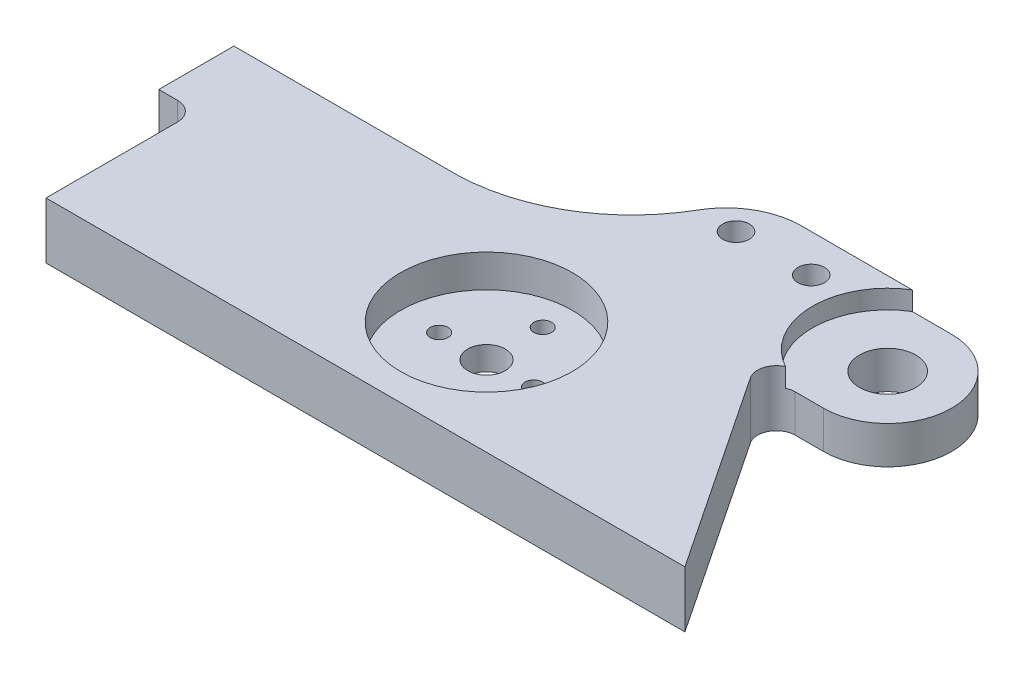
from build123d import *

# Parameters (mm, degrees)
SKETCH1_R           = 4.7625
SKETCH1_R_2         = 2.2479
SKETCH1_R_3         = 1.5
SKETCH1_R_4         = 3.175
BOSS_EXTRUDE1_DEPTH = 9.525
FILLET1_R           = 3.175
FILLET2_R           = 3.175
SKETCH2_R           = 14.5
CUT_EXTRUDE1_DEPTH  = 5.525
SKETCH3_R           = 12.7
CUT_EXTRUDE2_DEPTH  = 3.175


with BuildPart() as part:
    # Sketch1 → Boss-Extrude1 (new body)
    with BuildSketch(Plane(origin=(0, 0, 0), x_dir=(1, 0, 0), z_dir=(0, 1, 0))):
        with BuildLine():
            Line((0, 0), (38.1, 0))
            ThreePointArc((38.1, 0), (52.620300687, 4.403064286), (63.218539249, 15.261399634))
            ThreePointArc((63.218539249, 15.261399634), (67.86863694, 19.924564568), (74.228922018, 21.631986448))
            Line((74.228922018, 21.631986448), (99.628922018, 21.631986448))
            ThreePointArc((99.628922018, 21.631986448), (110.444915242, 10.815993224), (99.628922018, 0))
            Line((99.628922018, 0), (88.9, 0))
            Line((88.9, 0), (114.3, -38.1))
            Line((114.3, -38.1), (6.35, -38.1))
            Line((6.35, -38.1), (6.35, -12.7))
            Line((6.35, -12.7), (0, -12.7))
            Line((0, -12.7), (0, 0))
        make_face()
        with Locations((99.628922018, 10.815993224)):
            Circle(SKETCH1_R, mode=Mode.SUBTRACT)
        with Locations((69.568539249, 15.261399634)):
            Circle(SKETCH1_R_2, mode=Mode.SUBTRACT)
        with Locations((82.268539249, 15.261399634)):
            Circle(SKETCH1_R_2, mode=Mode.SUBTRACT)
        with Locations((69.720479044, -19.05)):
            Circle(SKETCH1_R_3, mode=Mode.SUBTRACT)
        with Locations((61.720479044, -28.55)):
            Circle(SKETCH1_R_3, mode=Mode.SUBTRACT)
        with Locations((53.720479044, -19.05)):
            Circle(SKETCH1_R_3, mode=Mode.SUBTRACT)
        with Locations((61.720479044, -9.55)):
            Circle(SKETCH1_R_3, mode=Mode.SUBTRACT)
        with Locations((61.720479044, -19.05)):
            Circle(SKETCH1_R_4, mode=Mode.SUBTRACT)
    extrude(amount=BOSS_EXTRUDE1_DEPTH)

    # Fillet1
    fillet1_edges = [part.edges().sort_by_distance(p)[0] for p in [
        (88.9, 4.7625, 0),
    ]]
    fillet(fillet1_edges, radius=FILLET1_R)

    # Fillet2
    fillet2_edges = [part.edges().sort_by_distance(p)[0] for p in [
        (6.35, 4.7625, 12.7),
    ]]
    fillet(fillet2_edges, radius=FILLET2_R)

    # Sketch2 → Cut-Extrude1 (cut)
    with BuildSketch(Plane(origin=(0, 9.525, 0), x_dir=(1, 0, 0), z_dir=(0, 1, 0))):
        with Locations((61.720479044, -19.05)):
            Circle(SKETCH2_R)
    extrude(amount=-CUT_EXTRUDE1_DEPTH, mode=Mode.SUBTRACT)

    # Sketch3 → Cut-Extrude2 (cut)
    with BuildSketch(Plane(origin=(0, 9.525, 0), x_dir=(1, 0, 0), z_dir=(0, 1, 0))):
        with Locations((99.628922018, 10.815993224)):
            Circle(SKETCH3_R)
    extrude(amount=-CUT_EXTRUDE2_DEPTH, mode=Mode.SUBTRACT)


solid = part.part
